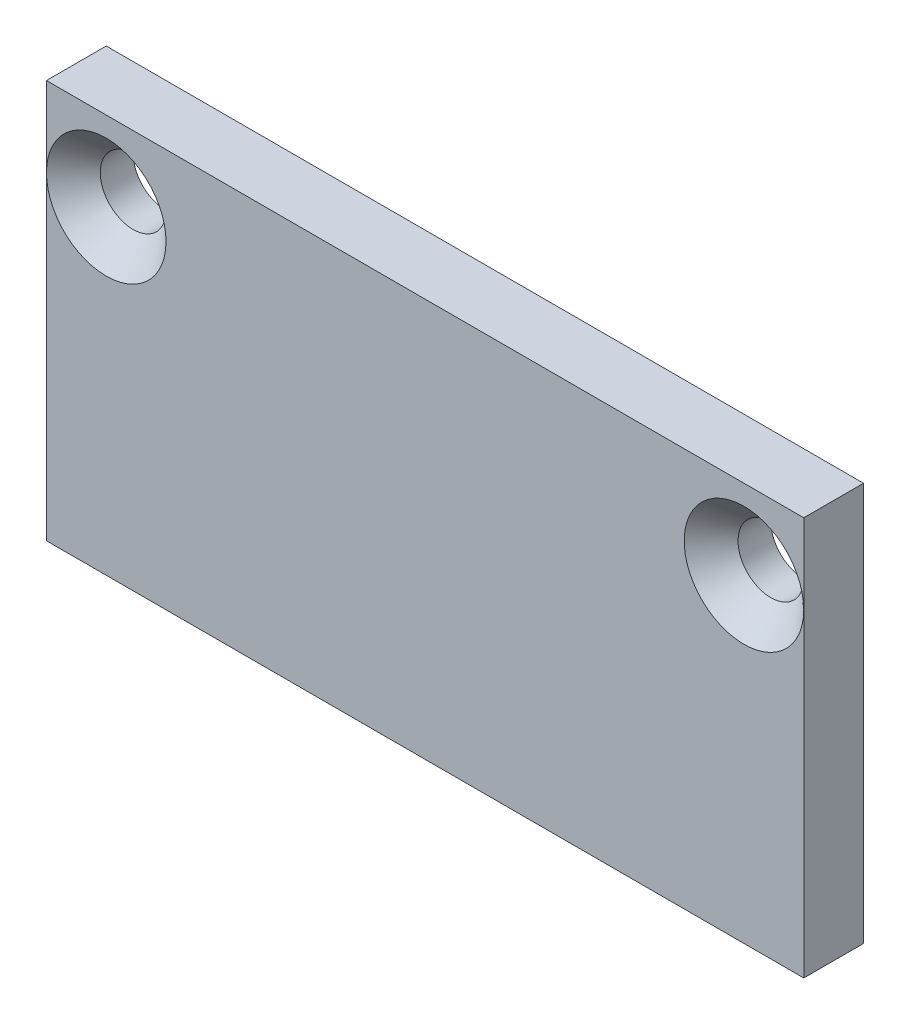
from build123d import *

# Parameters (mm, degrees)
SKETCH1_W                                       = 38
SKETCH1_H                                       = 20
BOSS_EXTRUDE1_DEPTH                             = 3
CSK_FOR_M3_FLAT_HEAD_MACHINE_SCREW1_D           = 3.3
CSK_FOR_M3_FLAT_HEAD_MACHINE_SCREW1_CSINK_D     = 6
CSK_FOR_M3_FLAT_HEAD_MACHINE_SCREW1_CSINK_ANGLE = 90


with BuildPart() as part:
    # Sketch1 → Boss-Extrude1 (new body)
    with BuildSketch(Plane.XY):
        with Locations((0, 10)):
            Rectangle(SKETCH1_W, SKETCH1_H)
    extrude(amount=BOSS_EXTRUDE1_DEPTH)

    # CSK for M3 Flat Head Machine Screw1 (through all)
    with Locations(Plane.XY.offset(3)):
        with Locations((-16, 16), (16, 16)):
            CounterSinkHole(CSK_FOR_M3_FLAT_HEAD_MACHINE_SCREW1_D / 2, CSK_FOR_M3_FLAT_HEAD_MACHINE_SCREW1_CSINK_D / 2, counter_sink_angle=CSK_FOR_M3_FLAT_HEAD_MACHINE_SCREW1_CSINK_ANGLE)


solid = part.part
